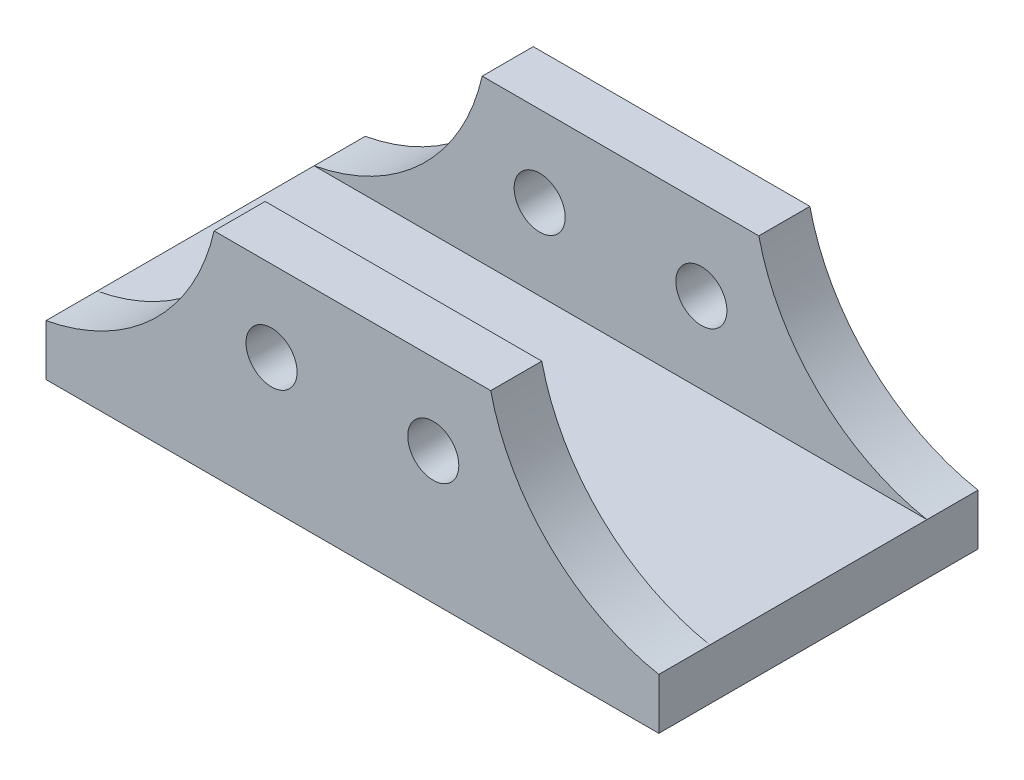
from build123d import *

# Parameters (mm, degrees)
SKETCH1_R                = 6
BOSS_EXTRUDE2_DEPTH      = 12
SKETCH3_W                = 144
SKETCH3_H                = 12
BOSS_EXTRUDE3_DEPTH      = 25.5
BOSS_EXTRUDE3_DEPTH_BACK = 25.5


with BuildPart() as part:
    # Sketch1 → Boss-Extrude2 (new body)
    with BuildSketch(Plane.XY):
        with BuildLine():
            Line((-32.5, 50), (32.5, 50))
            ThreePointArc((32.5, 50), (46.579087682, 25.10523588), (72, 12))
            Line((72, 12), (72, 0))
            Line((72, 0), (-72, 0))
            Line((-72, 0), (-72, 12))
            ThreePointArc((-72, 12), (-46.579087682, 25.10523588), (-32.5, 50))
        make_face()
        with Locations((19, 31)):
            Circle(SKETCH1_R, mode=Mode.SUBTRACT)
        with Locations((-19, 31)):
            Circle(SKETCH1_R, mode=Mode.SUBTRACT)
    extrude(amount=BOSS_EXTRUDE2_DEPTH)


with BuildPart() as body_2:
    # Mirror1: mirrored copy
    add(part.part.mirror(Plane.XY.offset(37.5)))


with BuildPart() as part_1:
    add(part.part)

    add(body_2.part)  # Boss-Extrude3 merges body 2
    # Sketch3 → Boss-Extrude3 (add, two sides)
    with BuildSketch(Plane.XY.offset(37.5)) as boss_extrude3_sk:
        with Locations((0, 6)):
            Rectangle(SKETCH3_W, SKETCH3_H)
    extrude(amount=BOSS_EXTRUDE3_DEPTH)
    extrude(boss_extrude3_sk.sketch, amount=-BOSS_EXTRUDE3_DEPTH_BACK)


solid = part_1.part
